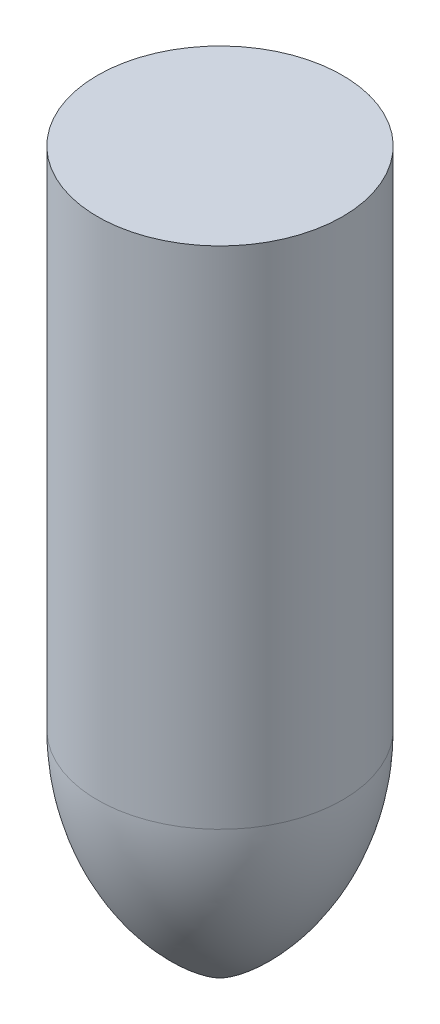
from build123d import *

# Parameters (mm, degrees)
BOSS_EXTRUDE1_DEPTH = 0.3175


with BuildPart() as part:
    # Sketch1 → Revolve1 (revolve)
    with BuildSketch(Plane.XY):
        with BuildLine():
            Line((0, 0), (0, -31.75))
            Line((0, -31.75), (6.985, -31.75))
            Line((6.985, -31.75), (6.985, -46.99))
            Line((6.985, -46.99), (0, -46.99))
            Line((0, -46.99), (0, -59.69))
            ThreePointArc((0, -59.69), (7.440867846, -52.14906734), (10.16, -41.91))
            Line((10.16, -41.91), (10.16, 0))
            Line((10.16, 0), (0, 0))
        make_face()
    revolve(axis=Axis((0, 0, 0), (0, -1, 0)))

    # Sketch2 → Boss-Extrude1 (add, symmetric)
    with BuildSketch(Plane.ZY.offset(10.16)):
        Polygon((0, -9.69718722), (3.175, -10.116322837), (3.175, -10.157027965), (0.569871795, -11.467860297), (3.175, -12.775512541), (3.175, -12.816853687), (0, -13.238533374), (0, -12.952325441), (2.284575321, -12.648309015), (0, -11.502205249), (0, -11.437967469), (2.289663462, -10.287411579), (0, -9.984031171), align=None)
        with BuildLine():
            Line((3.175, -13.889815425), (3.175, -14.174751323))
            Line((3.175, -14.174751323), (1.272671274, -14.174751323))
            add(Edge.make_bspline(
                [(1.272671274, -14.174751323), (1.245746607, -14.174708919), (1.19465241, -14.174628451), (1.121928309, -14.175165946), (1.057274007, -14.17667123), (1.000440284, -14.177620247), (0.951687935, -14.179731471), (0.910752832, -14.18145327), (0.877828805, -14.183667204), (0.858614679, -14.18632796), (0.850355569, -14.187471675)],
                knots=[0, 0, 0, 0, 8.0774e-05, 0.000153283, 0.000218169, 0.000274789, 0.0003238, 0.00036455, 0.00039772, 0.000422728, 0.000422728, 0.000422728, 0.000422728], degree=3))
            add(Edge.make_bspline(
                [(0.850355569, -14.187471675), (0.820556281, -14.192163811), (0.76263679, -14.201283698), (0.680205297, -14.224610995), (0.605659825, -14.25692725), (0.537513659, -14.296274088), (0.476779916, -14.34687506), (0.42039437, -14.407100278), (0.371681249, -14.48074792), (0.326865419, -14.562586225), (0.290896786, -14.650849248), (0.263685079, -14.741026506), (0.24710438, -14.831780533), (0.245184262, -14.892537384), (0.244230769, -14.922708054)],
                knots=[0, 0, 0, 0, 9.0451e-05, 0.000175805, 0.000256145, 0.0003337, 0.000410984, 0.000492446, 0.000580299, 0.000675068, 0.000772037, 0.00086561, 0.000957313, 0.001047771, 0.001047771, 0.001047771, 0.001047771], degree=3))
            add(Edge.make_bspline(
                [(0.244230769, -14.922708054), (0.245204851, -14.948610422), (0.247147389, -15.000265554), (0.259178203, -15.077014974), (0.280856369, -15.151766315), (0.308844052, -15.224872509), (0.34576491, -15.293445596), (0.388709972, -15.357436502), (0.438348236, -15.415159267), (0.49406505, -15.467214405), (0.556356409, -15.512791118), (0.625034629, -15.551246075), (0.699873946, -15.583656234), (0.752646426, -15.599539312), (0.779757612, -15.607699039)],
                knots=[0, 0, 0, 0, 7.7722e-05, 0.000154995, 0.000232312, 0.000310854, 0.000389384, 0.000465414, 0.000541643, 0.000617246, 0.000693701, 0.00077259, 0.00085293, 0.000937809, 0.000937809, 0.000937809, 0.000937809], degree=3))
            add(Edge.make_bspline(
                [(0.779757612, -15.607699039), (0.790959533, -15.610420581), (0.815921928, -15.616485274), (0.858123384, -15.622152236), (0.907915878, -15.628054585), (0.965657166, -15.632149944), (1.031153762, -15.63614248), (1.104746867, -15.638531053), (1.186169253, -15.639635076), (1.242990107, -15.639964079), (1.272671274, -15.640135938)],
                knots=[0, 0, 0, 0, 3.4562e-05, 7.7018e-05, 0.000127589, 0.000185003, 0.000250624, 0.000324446, 0.000405866, 0.000494911, 0.000494911, 0.000494911, 0.000494911], degree=3))
            Line((1.272671274, -15.640135938), (3.175, -15.640135938))
            Line((3.175, -15.640135938), (3.175, -15.925071836))
            Line((3.175, -15.925071836), (1.257406851, -15.925071836))
            add(Edge.make_bspline(
                [(1.257406851, -15.925071836), (1.222845807, -15.924843859), (1.155397828, -15.924398948), (1.056568546, -15.920462332), (0.962794378, -15.914367038), (0.874194974, -15.905152276), (0.790664825, -15.89497951), (0.712325967, -15.88042434), (0.63865312, -15.865208538), (0.569772421, -15.845962299), (0.504772509, -15.822744987), (0.441938957, -15.795561915), (0.381785405, -15.762299564), (0.323443079, -15.724342674), (0.266832051, -15.682200158), (0.213281778, -15.633625762), (0.161036613, -15.581134335), (0.111820563, -15.523620166), (0.066364321, -15.462111097), (0.027262862, -15.396497868), (-0.007070459, -15.32810167), (-0.034190465, -15.256189922), (-0.055181464, -15.181231017), (-0.070629365, -15.10322883), (-0.079442231, -15.021918103), (-0.080748687, -14.966613787), (-0.081410256, -14.938608494)],
                knots=[0, 0, 0, 0, 0.000103679, 0.000202335, 0.00029668, 0.000385534, 0.000469551, 0.000549023, 0.000624495, 0.000695173, 0.000763369, 0.000831435, 0.000900316, 0.000969294, 0.001040147, 0.001111768, 0.001185976, 0.001262205, 0.001338659, 0.001415122, 0.001491067, 0.001567964, 0.001645282, 0.001724363, 0.001806259, 0.001890273, 0.001890273, 0.001890273, 0.001890273], degree=3))
            add(Edge.make_bspline(
                [(-0.081410256, -14.938608494), (-0.080698362, -14.908065808), (-0.079301628, -14.848141168), (-0.071298134, -14.759841635), (-0.056222876, -14.675192329), (-0.037027784, -14.593299212), (-0.010553965, -14.515277218), (0.020377905, -14.440081022), (0.058366563, -14.368998504), (0.100633426, -14.300876494), (0.148190062, -14.237535466), (0.200024363, -14.179389964), (0.255305991, -14.126343996), (0.314633466, -14.079291679), (0.377545371, -14.037453448), (0.444219682, -14.001412468), (0.514630583, -13.970466882), (0.563573843, -13.954495211), (0.588316306, -13.946420994)],
                knots=[0, 0, 0, 0, 9.1642e-05, 0.000179801, 0.000265647, 0.00034941, 0.000431872, 0.000512549, 0.000593062, 0.000673357, 0.000752859, 0.000830344, 0.000906819, 0.000982409, 0.001057203, 0.00113319, 0.001209523, 0.001287564, 0.001287564, 0.001287564, 0.001287564], degree=3))
            add(Edge.make_bspline(
                [(0.588316306, -13.946420994), (0.605218713, -13.941724572), (0.64188041, -13.931537928), (0.70255601, -13.920629265), (0.772419543, -13.911458884), (0.851475789, -13.902835985), (0.939786025, -13.897747859), (1.03731197, -13.893287039), (1.14417155, -13.889783999), (1.218606718, -13.889804657), (1.257406851, -13.889815425)],
                knots=[0, 0, 0, 0, 5.2605e-05, 0.000114102, 0.000184711, 0.00026401, 0.000352601, 0.000450014, 0.000556912, 0.000673305, 0.000673305, 0.000673305, 0.000673305], degree=3))
            Line((1.257406851, -13.889815425), (3.175, -13.889815425))
        make_face()
        with BuildLine():
            Line((0, -16.779879528), (3.175, -16.779879528))
            Line((3.175, -16.779879528), (3.175, -17.420985297))
            add(Edge.make_bspline(
                [(3.175, -17.420985297), (3.17459962, -17.476746567), (3.173826087, -17.584477049), (3.168893457, -17.740152502), (3.160255733, -17.883986617), (3.147431171, -18.015897711), (3.132038103, -18.136097711), (3.112461964, -18.244394103), (3.089439099, -18.340962388), (3.069802659, -18.400352407), (3.060516827, -18.42843722)],
                knots=[0, 0, 0, 0, 0.000167284, 0.000323191, 0.000467206, 0.000599475, 0.00072073, 0.000830636, 0.000929515, 0.001018223, 0.001018223, 0.001018223, 0.001018223], degree=3))
            add(Edge.make_bspline(
                [(3.060516827, -18.42843722), (3.046518957, -18.46517171), (3.018840642, -18.537807675), (2.966629082, -18.64122876), (2.907470633, -18.738586936), (2.841292375, -18.830411804), (2.7662016, -18.914578081), (2.685458077, -18.994479022), (2.595762399, -19.066527811), (2.500160004, -19.133615807), (2.39768105, -19.1923189), (2.290405392, -19.24408821), (2.178533756, -19.288290161), (2.06125188, -19.322779857), (1.939685662, -19.351274219), (1.812914851, -19.370393258), (1.681678485, -19.383093262), (1.592619076, -19.384363316), (1.547430889, -19.385007733)],
                knots=[0, 0, 0, 0, 0.000117869, 0.000233066, 0.000346943, 0.000459403, 0.000572066, 0.000684957, 0.000799786, 0.000916762, 0.001035016, 0.001153638, 0.001273873, 0.001395407, 0.001520068, 0.001648162, 0.001779738, 0.001915263, 0.001915263, 0.001915263, 0.001915263], degree=3))
            add(Edge.make_bspline(
                [(1.547430889, -19.385007733), (1.508186899, -19.384436785), (1.430852516, -19.383311673), (1.316876375, -19.373221297), (1.206290292, -19.358526953), (1.099579946, -19.33588122), (0.996026491, -19.308055076), (0.896121688, -19.273709033), (0.799792307, -19.233005647), (0.707823021, -19.185781544), (0.620365974, -19.134144085), (0.538926149, -19.077526631), (0.461954668, -19.019178085), (0.392923345, -18.954599399), (0.327884052, -18.888240762), (0.270350979, -18.816583304), (0.217818032, -18.741961582), (0.170668663, -18.662938266), (0.129761362, -18.577619286), (0.094716805, -18.484840151), (0.065861131, -18.384103964), (0.041747667, -18.27556513), (0.022630438, -18.15901097), (0.009814934, -18.034334572), (0.001149302, -17.901725336), (0.000390539, -17.810667018), (0, -17.763798799)],
                knots=[0, 0, 0, 0, 0.000117706, 0.000231952, 0.000343037, 0.000452182, 0.00055895, 0.000664546, 0.000768855, 0.000872393, 0.000974489, 0.001073283, 0.001169843, 0.001263924, 0.001356586, 0.001448369, 0.001539239, 0.00163021, 0.001724085, 0.001822719, 0.001927382, 0.002038173, 0.002156118, 0.002281491, 0.002414041, 0.002554623, 0.002554623, 0.002554623, 0.002554623], degree=3))
            Line((0, -17.763798799), (0, -16.779879528))
        make_face()
        with BuildLine():
            Line((0.325641026, -17.064815425), (0.325641026, -17.429253526))
            add(Edge.make_bspline(
                [(0.325641026, -17.429253526), (0.325866084, -17.481621405), (0.326298955, -17.582344015), (0.330097347, -17.727176627), (0.336303961, -17.85951008), (0.344989925, -17.979363163), (0.356482168, -18.086668207), (0.369295473, -18.181649466), (0.385258875, -18.263995593), (0.399728674, -18.313824439), (0.406415264, -18.336850682)],
                knots=[0, 0, 0, 0, 0.000157102, 0.000302164, 0.000434608, 0.000554511, 0.000662606, 0.000758309, 0.000842005, 0.000913909, 0.000913909, 0.000913909, 0.000913909], degree=3))
            add(Edge.make_bspline(
                [(0.406415264, -18.336850682), (0.416621274, -18.365833023), (0.436789524, -18.423105463), (0.473592116, -18.505538729), (0.517132555, -18.582458134), (0.565816361, -18.655146963), (0.620397508, -18.723134527), (0.681041193, -18.786119219), (0.747076749, -18.844548694), (0.818751547, -18.897783791), (0.895602194, -18.945352154), (0.976650315, -18.986813253), (1.061700303, -19.021992383), (1.151058699, -19.0505981), (1.244641274, -19.072765886), (1.342201832, -19.088538004), (1.443770807, -19.098343034), (1.512851346, -19.099488106), (1.548066907, -19.100071836)],
                knots=[0, 0, 0, 0, 9.2159e-05, 0.000182117, 0.000270395, 0.000357008, 0.000444318, 0.000531585, 0.000619, 0.000708552, 0.000799095, 0.000889834, 0.000981372, 0.001074901, 0.001171009, 0.00126961, 0.001371186, 0.001476813, 0.001476813, 0.001476813, 0.001476813], degree=3))
            add(Edge.make_bspline(
                [(1.548066907, -19.100071836), (1.585199199, -19.099605714), (1.658145915, -19.098690015), (1.765183483, -19.08719964), (1.868115225, -19.070372452), (1.967015246, -19.046167853), (2.061754875, -19.014897599), (2.152869351, -18.977480206), (2.239186117, -18.932049617), (2.321436243, -18.880617387), (2.398374104, -18.822875289), (2.469098331, -18.759079466), (2.533740666, -18.689902605), (2.59240403, -18.615663521), (2.644045176, -18.535324225), (2.689984335, -18.450244218), (2.729016975, -18.359225034), (2.749769849, -18.295893754), (2.760316506, -18.263708655)],
                knots=[0, 0, 0, 0, 0.000111349, 0.000218745, 0.000322574, 0.000424076, 0.000523836, 0.000621636, 0.000719212, 0.000816091, 0.000912385, 0.001007407, 0.001101454, 0.001196118, 0.001290852, 0.001387602, 0.001485898, 0.001587471, 0.001587471, 0.001587471, 0.001587471], degree=3))
            add(Edge.make_bspline(
                [(2.760316506, -18.263708655), (2.767679266, -18.237082972), (2.783334513, -18.180469465), (2.800411815, -18.088086522), (2.815474468, -17.984114208), (2.828227118, -17.868090908), (2.837377759, -17.740148877), (2.844246023, -17.600189718), (2.848878468, -17.448152933), (2.849194796, -17.342758778), (2.849358974, -17.288057613)],
                knots=[0, 0, 0, 0, 8.2841e-05, 0.000176143, 0.000281561, 0.000398013, 0.000526208, 0.000666307, 0.00081838, 0.000982477, 0.000982477, 0.000982477, 0.000982477], degree=3))
            Line((2.849358974, -17.288057613), (2.849358974, -17.064815425))
            Line((2.849358974, -17.064815425), (0.325641026, -17.064815425))
        make_face(mode=Mode.SUBTRACT)
        with BuildLine():
            Line((0, -20.036289784), (3.175, -20.036289784))
            Line((3.175, -20.036289784), (3.175, -20.677395554))
            add(Edge.make_bspline(
                [(3.175, -20.677395554), (3.17459962, -20.733156823), (3.173826087, -20.840887306), (3.168893457, -20.996562759), (3.160255733, -21.140396873), (3.147431171, -21.272307968), (3.132038103, -21.392507968), (3.112461964, -21.500804359), (3.089439099, -21.597372644), (3.069802659, -21.656762664), (3.060516827, -21.684847477)],
                knots=[0, 0, 0, 0, 0.000167284, 0.000323191, 0.000467206, 0.000599475, 0.00072073, 0.000830636, 0.000929515, 0.001018223, 0.001018223, 0.001018223, 0.001018223], degree=3))
            add(Edge.make_bspline(
                [(3.060516827, -21.684847477), (3.046518957, -21.721581967), (3.018840642, -21.794217931), (2.966629082, -21.897639016), (2.907470633, -21.994997193), (2.841292375, -22.08682206), (2.7662016, -22.170988338), (2.685458077, -22.250889278), (2.595762399, -22.322938068), (2.500160004, -22.390026063), (2.39768105, -22.448729156), (2.290405392, -22.500498466), (2.178533756, -22.544700417), (2.06125188, -22.579190113), (1.939685662, -22.607684476), (1.812914851, -22.626803515), (1.681678485, -22.639503518), (1.592619076, -22.640773572), (1.547430889, -22.641417989)],
                knots=[0, 0, 0, 0, 0.000117869, 0.000233066, 0.000346943, 0.000459403, 0.000572066, 0.000684957, 0.000799786, 0.000916762, 0.001035016, 0.001153638, 0.001273873, 0.001395407, 0.001520068, 0.001648162, 0.001779738, 0.001915263, 0.001915263, 0.001915263, 0.001915263], degree=3))
            add(Edge.make_bspline(
                [(1.547430889, -22.641417989), (1.508186899, -22.640847042), (1.430852516, -22.639721929), (1.316876375, -22.629631553), (1.206290292, -22.614937209), (1.099579946, -22.592291477), (0.996026491, -22.564465332), (0.896121688, -22.53011929), (0.799792307, -22.489415903), (0.707823021, -22.442191801), (0.620365974, -22.390554341), (0.538926149, -22.333936888), (0.461954668, -22.275588341), (0.392923345, -22.211009655), (0.327884052, -22.144651018), (0.270350979, -22.07299356), (0.217818032, -21.998371839), (0.170668663, -21.919348522), (0.129761362, -21.834029542), (0.094716805, -21.741250408), (0.065861131, -21.640514221), (0.041747667, -21.531975386), (0.022630438, -21.415421226), (0.009814934, -21.290744828), (0.001149302, -21.158135593), (0.000390539, -21.067077275), (0, -21.020209055)],
                knots=[0, 0, 0, 0, 0.000117706, 0.000231952, 0.000343037, 0.000452182, 0.00055895, 0.000664546, 0.000768855, 0.000872393, 0.000974489, 0.001073283, 0.001169843, 0.001263924, 0.001356586, 0.001448369, 0.001539239, 0.00163021, 0.001724085, 0.001822719, 0.001927382, 0.002038173, 0.002156118, 0.002281491, 0.002414041, 0.002554623, 0.002554623, 0.002554623, 0.002554623], degree=3))
            Line((0, -21.020209055), (0, -20.036289784))
        make_face()
        with BuildLine():
            Line((0.325641026, -20.321225682), (0.325641026, -20.685663783))
            add(Edge.make_bspline(
                [(0.325641026, -20.685663783), (0.325866084, -20.738031662), (0.326298955, -20.838754272), (0.330097347, -20.983586884), (0.336303961, -21.115920336), (0.344989925, -21.23577342), (0.356482168, -21.343078463), (0.369295473, -21.438059722), (0.385258875, -21.520405849), (0.399728674, -21.570234696), (0.406415264, -21.593260938)],
                knots=[0, 0, 0, 0, 0.000157102, 0.000302164, 0.000434608, 0.000554511, 0.000662606, 0.000758309, 0.000842005, 0.000913909, 0.000913909, 0.000913909, 0.000913909], degree=3))
            add(Edge.make_bspline(
                [(0.406415264, -21.593260938), (0.416621274, -21.622243279), (0.436789524, -21.679515719), (0.473592116, -21.761948985), (0.517132555, -21.838868391), (0.565816361, -21.911557219), (0.620397508, -21.979544783), (0.681041193, -22.042529476), (0.747076749, -22.100958951), (0.818751547, -22.154194048), (0.895602194, -22.20176241), (0.976650315, -22.243223509), (1.061700303, -22.27840264), (1.151058699, -22.307008356), (1.244641274, -22.329176142), (1.342201832, -22.34494826), (1.443770807, -22.35475329), (1.512851346, -22.355898362), (1.548066907, -22.356482092)],
                knots=[0, 0, 0, 0, 9.2159e-05, 0.000182117, 0.000270395, 0.000357008, 0.000444318, 0.000531585, 0.000619, 0.000708552, 0.000799095, 0.000889834, 0.000981372, 0.001074901, 0.001171009, 0.00126961, 0.001371186, 0.001476813, 0.001476813, 0.001476813, 0.001476813], degree=3))
            add(Edge.make_bspline(
                [(1.548066907, -22.356482092), (1.585199199, -22.356015971), (1.658145915, -22.355100271), (1.765183483, -22.343609897), (1.868115225, -22.326782708), (1.967015246, -22.30257811), (2.061754875, -22.271307856), (2.152869351, -22.233890462), (2.239186117, -22.188459873), (2.321436243, -22.137027643), (2.398374104, -22.079285546), (2.469098331, -22.015489723), (2.533740666, -21.946312861), (2.59240403, -21.872073777), (2.644045176, -21.791734482), (2.689984335, -21.706654475), (2.729016975, -21.61563529), (2.749769849, -21.55230401), (2.760316506, -21.520118911)],
                knots=[0, 0, 0, 0, 0.000111349, 0.000218745, 0.000322574, 0.000424076, 0.000523836, 0.000621636, 0.000719212, 0.000816091, 0.000912385, 0.001007407, 0.001101454, 0.001196118, 0.001290852, 0.001387602, 0.001485898, 0.001587471, 0.001587471, 0.001587471, 0.001587471], degree=3))
            add(Edge.make_bspline(
                [(2.760316506, -21.520118911), (2.767679266, -21.493493228), (2.783334513, -21.436879721), (2.800411815, -21.344496779), (2.815474468, -21.240524465), (2.828227118, -21.124501164), (2.837377759, -20.996559134), (2.844246023, -20.856599974), (2.848878468, -20.70456319), (2.849194796, -20.599169034), (2.849358974, -20.544467869)],
                knots=[0, 0, 0, 0, 8.2841e-05, 0.000176143, 0.000281561, 0.000398013, 0.000526208, 0.000666307, 0.00081838, 0.000982477, 0.000982477, 0.000982477, 0.000982477], degree=3))
            Line((2.849358974, -20.544467869), (2.849358974, -20.321225682))
            Line((2.849358974, -20.321225682), (0.325641026, -20.321225682))
        make_face(mode=Mode.SUBTRACT)
        with BuildLine():
            Line((0.612484976, -22.967059015), (0.773397436, -23.235458454))
            add(Edge.make_bspline(
                [(0.773397436, -23.235458454), (0.731610458, -23.260421427), (0.651548221, -23.308249518), (0.543364142, -23.388033966), (0.451414185, -23.470704535), (0.376233263, -23.55687343), (0.317043201, -23.646014683), (0.275131177, -23.738710218), (0.24899097, -23.83464766), (0.245815892, -23.899938198), (0.244230769, -23.932533775)],
                knots=[0, 0, 0, 0, 0.00014596, 0.000279654, 0.00040257, 0.000516191, 0.000621858, 0.000722343, 0.000820302, 0.000917964, 0.000917964, 0.000917964, 0.000917964], degree=3))
            add(Edge.make_bspline(
                [(0.244230769, -23.932533775), (0.245006078, -23.960371144), (0.24654313, -24.015558794), (0.261312158, -24.096804501), (0.284001678, -24.17570958), (0.316496581, -24.250646821), (0.355810053, -24.320585705), (0.403298065, -24.381907088), (0.456453214, -24.434952844), (0.515797543, -24.478225141), (0.579399972, -24.511817706), (0.645268849, -24.536126216), (0.713114439, -24.55159712), (0.759111701, -24.553566256), (0.782301683, -24.554559015)],
                knots=[0, 0, 0, 0, 8.3437e-05, 0.000165414, 0.000246926, 0.00032927, 0.000409894, 0.000486986, 0.000561194, 0.000634468, 0.000706451, 0.000776277, 0.000844642, 0.000914154, 0.000914154, 0.000914154, 0.000914154], degree=3))
            add(Edge.make_bspline(
                [(0.782301683, -24.554559015), (0.808736596, -24.553221605), (0.862474913, -24.550502845), (0.941758884, -24.527523574), (1.020220001, -24.491374614), (1.068753292, -24.458025644), (1.093950321, -24.44071186)],
                knots=[0, 0, 0, 0, 7.9176e-05, 0.000160953, 0.000245754, 0.000337316, 0.000337316, 0.000337316, 0.000337316], degree=3))
            add(Edge.make_bspline(
                [(1.093950321, -24.44071186), (1.112172829, -24.426536618), (1.150541, -24.396690116), (1.206698105, -24.344668478), (1.266039619, -24.285212773), (1.32832457, -24.218025767), (1.39241548, -24.141771922), (1.459648329, -24.058017016), (1.529821059, -23.966327487), (1.5762256, -23.90170885), (1.600220353, -23.868295994)],
                knots=[0, 0, 0, 0, 6.9232e-05, 0.000145772, 0.000229422, 0.000321238, 0.000420509, 0.000528183, 0.000643433, 0.000766836, 0.000766836, 0.000766836, 0.000766836], degree=3))
            add(Edge.make_bspline(
                [(1.600220353, -23.868295994), (1.624018874, -23.834895825), (1.669519836, -23.771037245), (1.736962888, -23.68166364), (1.799017949, -23.601851116), (1.854820612, -23.531192988), (1.906804708, -23.471517272), (1.952184181, -23.42064239), (1.993382241, -23.380445309), (2.020086685, -23.358076582), (2.032076322, -23.348033574)],
                knots=[0, 0, 0, 0, 0.00012303, 0.000235223, 0.000335855, 0.000426344, 0.000505264, 0.000573246, 0.000630819, 0.000677729, 0.000677729, 0.000677729, 0.000677729], degree=3))
            add(Edge.make_bspline(
                [(2.032076322, -23.348033574), (2.050764406, -23.333997766), (2.08751703, -23.306394464), (2.144961722, -23.269958159), (2.203765684, -23.238989061), (2.264086933, -23.214711803), (2.325078618, -23.194268233), (2.387536534, -23.180517824), (2.451180424, -23.171907771), (2.494009814, -23.17102604), (2.51544972, -23.170584656)],
                knots=[0, 0, 0, 0, 7.0095e-05, 0.000137851, 0.00020385, 0.000269165, 0.000332722, 0.000396603, 0.00046074, 0.000525028, 0.000525028, 0.000525028, 0.000525028], degree=3))
            add(Edge.make_bspline(
                [(2.51544972, -23.170584656), (2.549043828, -23.171763502), (2.615513993, -23.174095998), (2.71256544, -23.193983401), (2.805506424, -23.225006435), (2.892289736, -23.269874826), (2.972712435, -23.32534877), (3.045545792, -23.390910259), (3.107295849, -23.468750095), (3.160622393, -23.554631653), (3.202725928, -23.648028992), (3.234655176, -23.74572282), (3.25250558, -23.848141526), (3.255095909, -23.917628339), (3.256410256, -23.952886339)],
                knots=[0, 0, 0, 0, 0.000100692, 0.000199231, 0.000295975, 0.000393825, 0.00049121, 0.000588457, 0.000686595, 0.000788262, 0.00089101, 0.00099319, 0.001095873, 0.001201643, 0.001201643, 0.001201643, 0.001201643], degree=3))
            add(Edge.make_bspline(
                [(3.256410256, -23.952886339), (3.255143973, -23.990306207), (3.25263278, -24.06451428), (3.230016787, -24.173875837), (3.193484798, -24.279370901), (3.151408807, -24.364289258), (3.109573291, -24.43063508), (3.07145259, -24.481228039), (3.027570263, -24.532497701), (2.977804852, -24.584856145), (2.921701083, -24.637416623), (2.859642795, -24.69095932), (2.792009354, -24.74560948), (2.743727127, -24.780766581), (2.718975361, -24.798789784)],
                knots=[0, 0, 0, 0, 0.000112158, 0.000222422, 0.00033345, 0.000446371, 0.000505835, 0.000568546, 0.000636222, 0.000708201, 0.000785138, 0.00086675, 0.00095406, 0.001045903, 0.001045903, 0.001045903, 0.001045903], degree=3))
            Line((2.718975361, -24.798789784), (2.523717949, -24.541202645))
            add(Edge.make_bspline(
                [(2.523717949, -24.541202645), (2.543755547, -24.525648835), (2.582343276, -24.495695833), (2.636382962, -24.450221225), (2.685746508, -24.40735996), (2.728622649, -24.365132071), (2.767359855, -24.325767934), (2.800523886, -24.287561476), (2.82844464, -24.251064093), (2.858226368, -24.205052766), (2.887935846, -24.147099434), (2.912540365, -24.074423002), (2.927858393, -23.998681032), (2.929788286, -23.947234974), (2.930769231, -23.921085457)],
                knots=[0, 0, 0, 0, 7.6089e-05, 0.000146529, 0.000211865, 0.000272136, 0.000327011, 0.000377509, 0.000423812, 0.00046474, 0.000541824, 0.000618456, 0.000694294, 0.00077269, 0.00077269, 0.00077269, 0.00077269], degree=3))
            add(Edge.make_bspline(
                [(2.930769231, -23.921085457), (2.929670046, -23.888286326), (2.927550371, -23.825036292), (2.904400099, -23.735238006), (2.867949411, -23.654417089), (2.816863681, -23.584972976), (2.756338209, -23.527154433), (2.686688819, -23.485330195), (2.609779068, -23.460156831), (2.556129137, -23.457084992), (2.52880609, -23.455520554)],
                knots=[0, 0, 0, 0, 9.8196e-05, 0.000189362, 0.000276162, 0.00036267, 0.000446363, 0.000525662, 0.000604507, 0.000686336, 0.000686336, 0.000686336, 0.000686336], degree=3))
            add(Edge.make_bspline(
                [(2.52880609, -23.455520554), (2.511800157, -23.455893778), (2.477760483, -23.456640836), (2.427337276, -23.466357128), (2.377361658, -23.480134539), (2.327611408, -23.500298628), (2.276916114, -23.52745875), (2.225412647, -23.564388351), (2.171800668, -23.610588802), (2.136966245, -23.646048631), (2.11857472, -23.664770353)],
                knots=[0, 0, 0, 0, 5.0945e-05, 0.000101973, 0.000153518, 0.000206311, 0.000262656, 0.00032565, 0.000396016, 0.00047472, 0.00047472, 0.00047472, 0.00047472], degree=3))
            add(Edge.make_bspline(
                [(2.11857472, -23.664770353), (2.11237256, -23.671720313), (2.09763765, -23.688231825), (2.073514653, -23.718417843), (2.043757852, -23.758280239), (2.006939358, -23.806778093), (1.964229746, -23.864805628), (1.916175112, -23.932369225), (1.861215445, -24.008715759), (1.822791105, -24.062892068), (1.802473958, -24.091538182)],
                knots=[0, 0, 0, 0, 2.7941e-05, 6.6382e-05, 0.000115865, 0.000177177, 0.00024905, 0.000332006, 0.000425904, 0.000531263, 0.000531263, 0.000531263, 0.000531263], degree=3))
            add(Edge.make_bspline(
                [(1.802473958, -24.091538182), (1.777399296, -24.125996832), (1.728845689, -24.192721231), (1.655897179, -24.287660607), (1.584552418, -24.373742848), (1.515267017, -24.451270182), (1.448566533, -24.521008521), (1.383648505, -24.582184167), (1.320978021, -24.635420463), (1.240630042, -24.69273304), (1.141950058, -24.751296205), (1.021047656, -24.801589572), (0.899675279, -24.833301787), (0.818098792, -24.837448805), (0.777849559, -24.839494913)],
                knots=[0, 0, 0, 0, 0.000127846, 0.000247556, 0.00035912, 0.000463173, 0.000559432, 0.00064852, 0.000730687, 0.00080588, 0.000944415, 0.001073869, 0.001197738, 0.001318375, 0.001318375, 0.001318375, 0.001318375], degree=3))
            add(Edge.make_bspline(
                [(0.777849559, -24.839494913), (0.749385124, -24.838898463), (0.693009013, -24.837717147), (0.610224359, -24.824150277), (0.529835635, -24.8042481), (0.452763675, -24.774345681), (0.377977195, -24.737562881), (0.306165081, -24.692130844), (0.238314528, -24.637362553), (0.173013571, -24.576489815), (0.114028034, -24.508839971), (0.061272077, -24.437509684), (0.017115672, -24.362035872), (-0.018430348, -24.282783834), (-0.046671844, -24.200191978), (-0.066971242, -24.114173384), (-0.079458394, -24.024488517), (-0.080752372, -23.963527543), (-0.081410256, -23.932533775)],
                knots=[0, 0, 0, 0, 8.5312e-05, 0.000168967, 0.000251033, 0.000333365, 0.00041642, 0.000500762, 0.000587675, 0.000677662, 0.000768247, 0.000856532, 0.000943472, 0.001030007, 0.001116695, 0.001204937, 0.001294795, 0.001387732, 0.001387732, 0.001387732, 0.001387732], degree=3))
            add(Edge.make_bspline(
                [(-0.081410256, -23.932533775), (-0.080941228, -23.908554201), (-0.080009079, -23.86089705), (-0.07196351, -23.790595567), (-0.060164584, -23.721585033), (-0.042175497, -23.654731958), (-0.019835908, -23.5892039), (0.007515688, -23.525584955), (0.040076371, -23.463720559), (0.077900074, -23.40353847), (0.12149056, -23.344471601), (0.171865716, -23.286822771), (0.228677591, -23.229932471), (0.292508805, -23.174843589), (0.362677386, -23.120540693), (0.439771279, -23.068033643), (0.523390283, -23.016253241), (0.582232045, -22.983763372), (0.612484976, -22.967059015)],
                knots=[0, 0, 0, 0, 7.1915e-05, 0.000142924, 0.000212043, 0.000281773, 0.00035036, 0.000419592, 0.000489294, 0.00055988, 0.000632642, 0.000709287, 0.000789339, 0.000873642, 0.000962058, 0.001055381, 0.001153341, 0.001257002, 0.001257002, 0.001257002, 0.001257002], degree=3))
        make_face()
        with BuildLine():
            Line((3.175, -25.490776964), (3.175, -25.775712861))
            Line((3.175, -25.775712861), (1.272671274, -25.775712861))
            add(Edge.make_bspline(
                [(1.272671274, -25.775712861), (1.245746607, -25.775670458), (1.19465241, -25.77558999), (1.121928309, -25.776127485), (1.057274007, -25.777632769), (1.000440284, -25.778581785), (0.951687935, -25.780693009), (0.910752832, -25.782414809), (0.877828805, -25.784628742), (0.858614679, -25.787289499), (0.850355569, -25.788433214)],
                knots=[0, 0, 0, 0, 8.0774e-05, 0.000153283, 0.000218169, 0.000274789, 0.0003238, 0.00036455, 0.00039772, 0.000422728, 0.000422728, 0.000422728, 0.000422728], degree=3))
            add(Edge.make_bspline(
                [(0.850355569, -25.788433214), (0.820556281, -25.79312535), (0.76263679, -25.802245236), (0.680205297, -25.825572534), (0.605659825, -25.857888788), (0.537513659, -25.897235627), (0.476779916, -25.947836599), (0.42039437, -26.008061817), (0.371681249, -26.081709459), (0.326865419, -26.163547763), (0.290896786, -26.251810786), (0.263685079, -26.341988045), (0.24710438, -26.432742072), (0.245184262, -26.493498923), (0.244230769, -26.523669592)],
                knots=[0, 0, 0, 0, 9.0451e-05, 0.000175805, 0.000256145, 0.0003337, 0.000410984, 0.000492446, 0.000580299, 0.000675068, 0.000772037, 0.00086561, 0.000957313, 0.001047771, 0.001047771, 0.001047771, 0.001047771], degree=3))
            add(Edge.make_bspline(
                [(0.244230769, -26.523669592), (0.245204851, -26.549571961), (0.247147389, -26.601227093), (0.259178203, -26.677976512), (0.280856369, -26.752727854), (0.308844052, -26.825834047), (0.34576491, -26.894407135), (0.388709972, -26.958398041), (0.438348236, -27.016120806), (0.49406505, -27.068175943), (0.556356409, -27.113752656), (0.625034629, -27.152207614), (0.699873946, -27.184617772), (0.752646426, -27.20050085), (0.779757612, -27.208660578)],
                knots=[0, 0, 0, 0, 7.7722e-05, 0.000154995, 0.000232312, 0.000310854, 0.000389384, 0.000465414, 0.000541643, 0.000617246, 0.000693701, 0.00077259, 0.00085293, 0.000937809, 0.000937809, 0.000937809, 0.000937809], degree=3))
            add(Edge.make_bspline(
                [(0.779757612, -27.208660578), (0.790959533, -27.21138212), (0.815921928, -27.217446813), (0.858123384, -27.223113775), (0.907915878, -27.229016123), (0.965657166, -27.233111483), (1.031153762, -27.237104019), (1.104746867, -27.239492592), (1.186169253, -27.240596614), (1.242990107, -27.240925617), (1.272671274, -27.241097477)],
                knots=[0, 0, 0, 0, 3.4562e-05, 7.7018e-05, 0.000127589, 0.000185003, 0.000250624, 0.000324446, 0.000405866, 0.000494911, 0.000494911, 0.000494911, 0.000494911], degree=3))
            Line((1.272671274, -27.241097477), (3.175, -27.241097477))
            Line((3.175, -27.241097477), (3.175, -27.526033374))
            Line((3.175, -27.526033374), (1.257406851, -27.526033374))
            add(Edge.make_bspline(
                [(1.257406851, -27.526033374), (1.222845807, -27.525805397), (1.155397828, -27.525360487), (1.056568546, -27.521423871), (0.962794378, -27.515328577), (0.874194974, -27.506113814), (0.790664825, -27.495941048), (0.712325967, -27.481385879), (0.63865312, -27.466170077), (0.569772421, -27.446923837), (0.504772509, -27.423706525), (0.441938957, -27.396523453), (0.381785405, -27.363261103), (0.323443079, -27.325304213), (0.266832051, -27.283161697), (0.213281778, -27.2345873), (0.161036613, -27.182095874), (0.111820563, -27.124581705), (0.066364321, -27.063072636), (0.027262862, -26.997459407), (-0.007070459, -26.929063209), (-0.034190465, -26.85715146), (-0.055181464, -26.782192556), (-0.070629365, -26.704190369), (-0.079442231, -26.622879642), (-0.080748687, -26.567575326), (-0.081410256, -26.539570033)],
                knots=[0, 0, 0, 0, 0.000103679, 0.000202335, 0.00029668, 0.000385534, 0.000469551, 0.000549023, 0.000624495, 0.000695173, 0.000763369, 0.000831435, 0.000900316, 0.000969294, 0.001040147, 0.001111768, 0.001185976, 0.001262205, 0.001338659, 0.001415122, 0.001491067, 0.001567964, 0.001645282, 0.001724363, 0.001806259, 0.001890273, 0.001890273, 0.001890273, 0.001890273], degree=3))
            add(Edge.make_bspline(
                [(-0.081410256, -26.539570033), (-0.080698362, -26.509027347), (-0.079301628, -26.449102706), (-0.071298134, -26.360803174), (-0.056222876, -26.276153867), (-0.037027784, -26.19426075), (-0.010553965, -26.116238756), (0.020377905, -26.04104256), (0.058366563, -25.969960042), (0.100633426, -25.901838033), (0.148190062, -25.838497004), (0.200024363, -25.780351503), (0.255305991, -25.727305534), (0.314633466, -25.680253217), (0.377545371, -25.638414986), (0.444219682, -25.602374007), (0.514630583, -25.571428421), (0.563573843, -25.555456749), (0.588316306, -25.547382533)],
                knots=[0, 0, 0, 0, 9.1642e-05, 0.000179801, 0.000265647, 0.00034941, 0.000431872, 0.000512549, 0.000593062, 0.000673357, 0.000752859, 0.000830344, 0.000906819, 0.000982409, 0.001057203, 0.00113319, 0.001209523, 0.001287564, 0.001287564, 0.001287564, 0.001287564], degree=3))
            add(Edge.make_bspline(
                [(0.588316306, -25.547382533), (0.605218713, -25.542686111), (0.64188041, -25.532499467), (0.70255601, -25.521590804), (0.772419543, -25.512420423), (0.851475789, -25.503797523), (0.939786025, -25.498709397), (1.03731197, -25.494248578), (1.14417155, -25.490745538), (1.218606718, -25.490766196), (1.257406851, -25.490776964)],
                knots=[0, 0, 0, 0, 5.2605e-05, 0.000114102, 0.000184711, 0.00026401, 0.000352601, 0.000450014, 0.000556912, 0.000673305, 0.000673305, 0.000673305, 0.000673305], degree=3))
            Line((1.257406851, -25.490776964), (3.175, -25.490776964))
        make_face()
        with BuildLine():
            Line((3.175, -28.380841066), (3.175, -29.000322236))
            add(Edge.make_bspline(
                [(3.175, -29.000322236), (3.174840569, -29.030646641), (3.174531553, -29.089422886), (3.169738998, -29.17489338), (3.163204241, -29.254947658), (3.152835514, -29.329608937), (3.140324401, -29.398842717), (3.125173468, -29.462857645), (3.107006469, -29.521450158), (3.078117342, -29.591402426), (3.035188468, -29.671159026), (2.97175327, -29.757517568), (2.894163107, -29.831362842), (2.806639555, -29.895031859), (2.710359248, -29.945651446), (2.607616984, -29.982272165), (2.499737975, -30.005456809), (2.425675949, -30.007841175), (2.388246194, -30.009046195)],
                knots=[0, 0, 0, 0, 9.0959e-05, 0.000176302, 0.000256745, 0.000331852, 0.000402335, 0.000467743, 0.000529095, 0.000586142, 0.000694565, 0.000800018, 0.00090617, 0.001014562, 0.001123809, 0.001231237, 0.001341005, 0.001453163, 0.001453163, 0.001453163, 0.001453163], degree=3))
            add(Edge.make_bspline(
                [(2.388246194, -30.009046195), (2.353176863, -30.008073656), (2.284262321, -30.006162526), (2.183629545, -29.987265241), (2.087441059, -29.95912988), (1.996882669, -29.918285649), (1.913118245, -29.865747328), (1.836645597, -29.802523523), (1.769317975, -29.727247318), (1.731835083, -29.670758024), (1.712795473, -29.642064023)],
                knots=[0, 0, 0, 0, 0.000105099, 0.000206529, 0.000306133, 0.000405196, 0.000503491, 0.000601945, 0.000701931, 0.00080515, 0.00080515, 0.00080515, 0.00080515], degree=3))
            add(Edge.make_bspline(
                [(1.712795473, -29.642064023), (1.698958624, -29.678138452), (1.672485305, -29.74715777), (1.625426118, -29.842205762), (1.574819095, -29.924424385), (1.519261182, -29.993904137), (1.458626779, -30.052430076), (1.394130058, -30.104987584), (1.322595753, -30.149018992), (1.246060754, -30.186845683), (1.165062223, -30.216614892), (1.079970596, -30.237678561), (0.991737352, -30.25062116), (0.931597431, -30.252386013), (0.901236979, -30.253276964)],
                knots=[0, 0, 0, 0, 0.000115862, 0.000221672, 0.000317675, 0.000404986, 0.000487741, 0.000570085, 0.000654088, 0.000739136, 0.000825861, 0.000912399, 0.001001716, 0.001092775, 0.001092775, 0.001092775, 0.001092775], degree=3))
            add(Edge.make_bspline(
                [(0.901236979, -30.253276964), (0.870242921, -30.252390547), (0.809261243, -30.250646497), (0.719673718, -30.237787209), (0.634071385, -30.21599292), (0.551845598, -30.186046377), (0.473461785, -30.146740301), (0.397938254, -30.099937006), (0.327286901, -30.042971466), (0.259827559, -29.979475306), (0.199209214, -29.907559076), (0.145242055, -29.82997835), (0.100655993, -29.745617263), (0.063670766, -29.655784031), (0.035007404, -29.55988171), (0.015107968, -29.458265884), (0.001668484, -29.350914468), (0.000565598, -29.277245093), (0, -29.239464864)],
                knots=[0, 0, 0, 0, 9.2965e-05, 0.000182912, 0.000270839, 0.000357564, 0.000444886, 0.000533473, 0.000623565, 0.000716687, 0.000810992, 0.0009052, 0.000999667, 0.001096636, 0.001196239, 0.001299394, 0.001406999, 0.001520275, 0.001520275, 0.001520275, 0.001520275], degree=3))
            Line((0, -29.239464864), (0, -28.380841066))
            Line((0, -28.380841066), (3.175, -28.380841066))
        make_face()
        with BuildLine():
            Line((2.849358974, -28.665776964), (1.831730769, -28.665776964))
            Line((1.831730769, -28.665776964), (1.831730769, -28.85721827))
            add(Edge.make_bspline(
                [(1.831730769, -28.85721827), (1.832090538, -28.885202786), (1.832785683, -28.939274575), (1.834839707, -29.017787146), (1.840339204, -29.090483142), (1.84615583, -29.157613061), (1.855112242, -29.218726968), (1.866072375, -29.274029456), (1.877562384, -29.324017316), (1.897157761, -29.381638094), (1.925824047, -29.446979293), (1.971357883, -29.516192763), (2.024118751, -29.578200752), (2.086120663, -29.629976642), (2.153813016, -29.672700802), (2.227201843, -29.701213051), (2.30342207, -29.721436415), (2.355885289, -29.723209873), (2.382522035, -29.724110297)],
                knots=[0, 0, 0, 0, 8.3964e-05, 0.000162235, 0.000235554, 0.000302638, 0.000364342, 0.000420722, 0.000471782, 0.000518041, 0.000603156, 0.000685012, 0.000765726, 0.00084651, 0.000926469, 0.001004655, 0.001081939, 0.001161647, 0.001161647, 0.001161647, 0.001161647], degree=3))
            add(Edge.make_bspline(
                [(2.382522035, -29.724110297), (2.400152285, -29.723659957), (2.434735944, -29.722776566), (2.484956763, -29.714736659), (2.532793865, -29.703070674), (2.577147029, -29.684844848), (2.619276899, -29.662806057), (2.657312206, -29.634137589), (2.69333675, -29.601761168), (2.7260278, -29.563738213), (2.755319108, -29.520252834), (2.78109289, -29.470890694), (2.801423987, -29.415062385), (2.819662063, -29.354033749), (2.8323173, -29.286828079), (2.842898763, -29.214102064), (2.848277614, -29.135238749), (2.848990481, -29.080678708), (2.849358974, -29.052475682)],
                knots=[0, 0, 0, 0, 5.2851e-05, 0.000103672, 0.000152264, 0.000200215, 0.000247169, 0.000294491, 0.000342665, 0.000392266, 0.000444482, 0.000499669, 0.000558849, 0.000622451, 0.000690555, 0.000763772, 0.000842846, 0.000927458, 0.000927458, 0.000927458, 0.000927458], degree=3))
            Line((2.849358974, -29.052475682), (2.849358974, -28.665776964))
        make_face(mode=Mode.SUBTRACT)
        with BuildLine():
            Line((1.506089744, -28.665776964), (0.325641026, -28.665776964))
            Line((0.325641026, -28.665776964), (0.325641026, -29.071556211))
            add(Edge.make_bspline(
                [(0.325641026, -29.071556211), (0.325987924, -29.100602095), (0.326656523, -29.156584207), (0.328863052, -29.237409834), (0.333776664, -29.31212064), (0.341787161, -29.380759614), (0.350110765, -29.443930966), (0.361631037, -29.501007089), (0.374728192, -29.552075483), (0.394996661, -29.611283056), (0.426430338, -29.677997395), (0.474134308, -29.749842021), (0.530217889, -29.814355546), (0.59594578, -29.868511419), (0.666872541, -29.913231216), (0.742627202, -29.944595818), (0.820898714, -29.964762808), (0.874403648, -29.967145913), (0.901236979, -29.968341066)],
                knots=[0, 0, 0, 0, 8.7144e-05, 0.000167958, 0.000242546, 0.000311658, 0.000375251, 0.000433626, 0.000486231, 0.000533296, 0.00062121, 0.000706588, 0.000791309, 0.000876652, 0.000961195, 0.001041871, 0.001121777, 0.001202167, 0.001202167, 0.001202167, 0.001202167], degree=3))
            add(Edge.make_bspline(
                [(0.901236979, -29.968341066), (0.918015251, -29.968096781), (0.951301161, -29.96761215), (1.000178868, -29.960028489), (1.047736368, -29.949448787), (1.093254521, -29.93412847), (1.137474006, -29.914810791), (1.179624587, -29.890567837), (1.2207141, -29.862571818), (1.272600844, -29.818776794), (1.332403535, -29.755136286), (1.390946081, -29.664682812), (1.438161495, -29.561839406), (1.458208789, -29.487247114), (1.468564704, -29.448714664)],
                knots=[0, 0, 0, 0, 5.0282e-05, 9.9752e-05, 0.000148043, 0.000196314, 0.000243585, 0.000292575, 0.000341972, 0.000392542, 0.000496043, 0.000602591, 0.000714445, 0.000833969, 0.000833969, 0.000833969, 0.000833969], degree=3))
            add(Edge.make_bspline(
                [(1.468564704, -29.448714664), (1.471699169, -29.433266856), (1.478495336, -29.399772821), (1.485664702, -29.345155667), (1.492095856, -29.282593333), (1.496728084, -29.21235322), (1.501700699, -29.134155974), (1.503565733, -29.048026718), (1.505842106, -28.953904562), (1.506005086, -28.888597115), (1.506089744, -28.854674199)],
                knots=[0, 0, 0, 0, 4.7275e-05, 0.000102503, 0.000165156, 0.000235937, 0.000313659, 0.000400195, 0.000494345, 0.00059611, 0.00059611, 0.00059611, 0.00059611], degree=3))
            Line((1.506089744, -28.854674199), (1.506089744, -28.665776964))
        make_face(mode=Mode.SUBTRACT)
    extrude(amount=BOSS_EXTRUDE1_DEPTH, both=True)


solid = part.part
